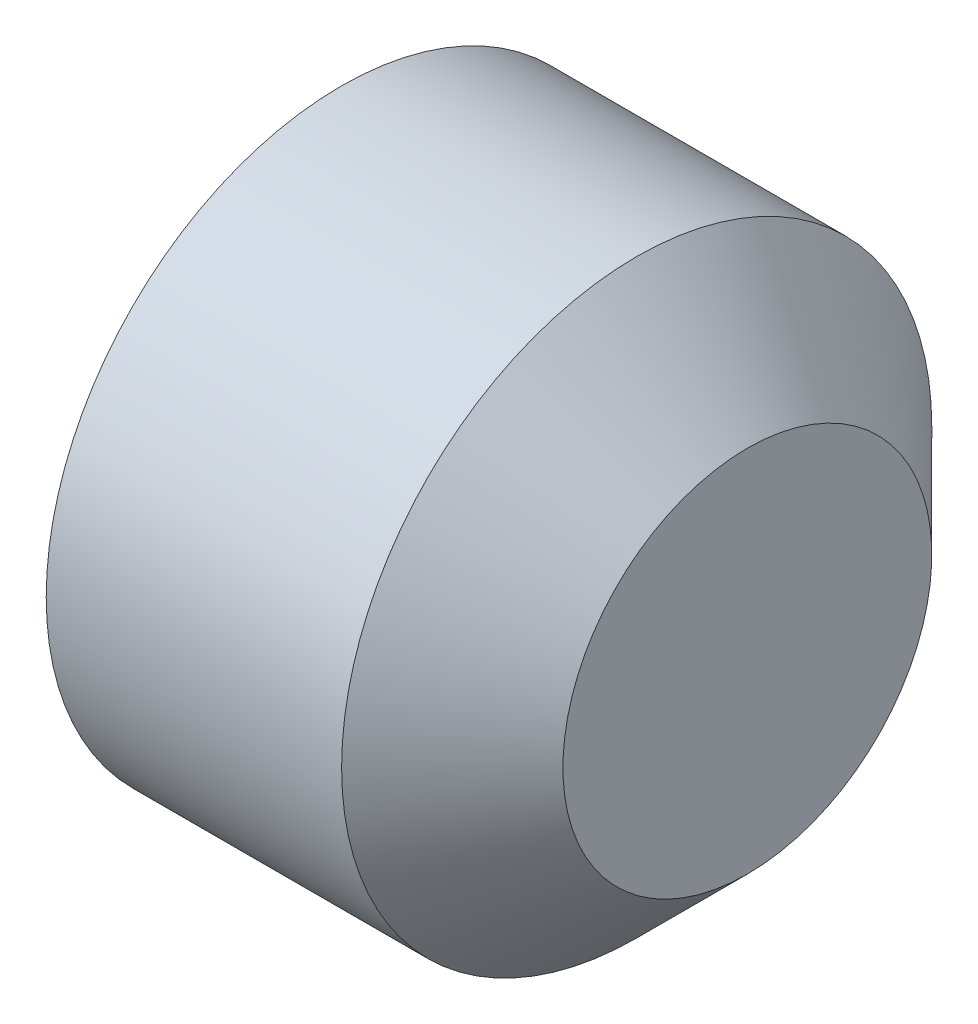
from build123d import *

# Parameters (mm, degrees)
CUT_EXTRUDE1_DEPTH = 1.5


with BuildPart() as part:
    # Sketch1 → Revolve1 (revolve)
    with BuildSketch(Plane.XY):
        Polygon((3, 0), (3, -1.25), (2.25, -2), (0.247971941, -2), (0, -1.5705), (0, -1.154700538), (0.666666667, 0), align=None)
    revolve(axis=Axis((0.666666667, 0, 0), (1, 0, 0)))

    # Sketch2 → Cut-Extrude1 (cut)
    with BuildSketch(Plane(origin=(0, 0, 0), x_dir=(0, 0, -1), z_dir=(1, 0, 0))):
        Polygon((-1.154700538, 0), (-0.577350269, -1), (0.577350269, -1), (1.154700538, 0), (0.577350269, 1), (-0.577350269, 1), align=None)
    extrude(amount=CUT_EXTRUDE1_DEPTH, mode=Mode.SUBTRACT)


solid = part.part
